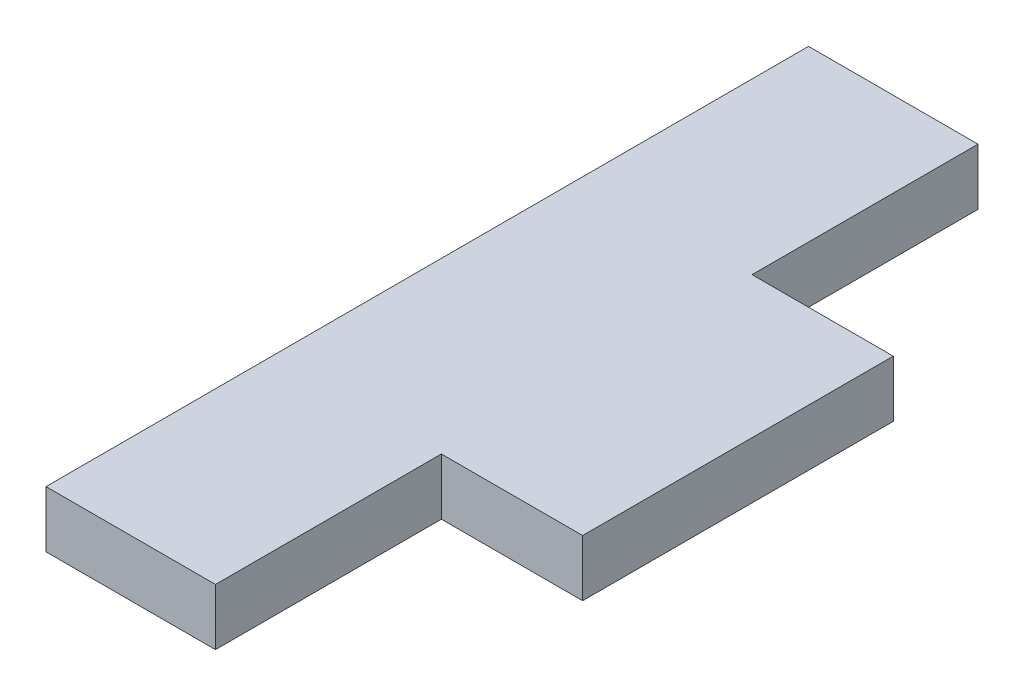
from build123d import *

# Parameters (mm, degrees)
BOSS_EXTRUDE1_DEPTH = 10


with BuildPart() as part:
    # Sketch1 → Boss-Extrude1 (new body)
    with BuildSketch(Plane(origin=(0, 0, 0), x_dir=(1, 0, 0), z_dir=(0, 1, 0))):
        Polygon((4.547134935, 64.006469501), (4.547134935, 24.006469501), (29.547134935, 24.006469501), (29.547134935, -30.993530499), (4.547134935, -30.993530499), (4.547134935, -70.993530499), (-25.452865065, -70.993530499), (-25.452865065, 64.006469501), align=None)
    extrude(amount=BOSS_EXTRUDE1_DEPTH)


solid = part.part
